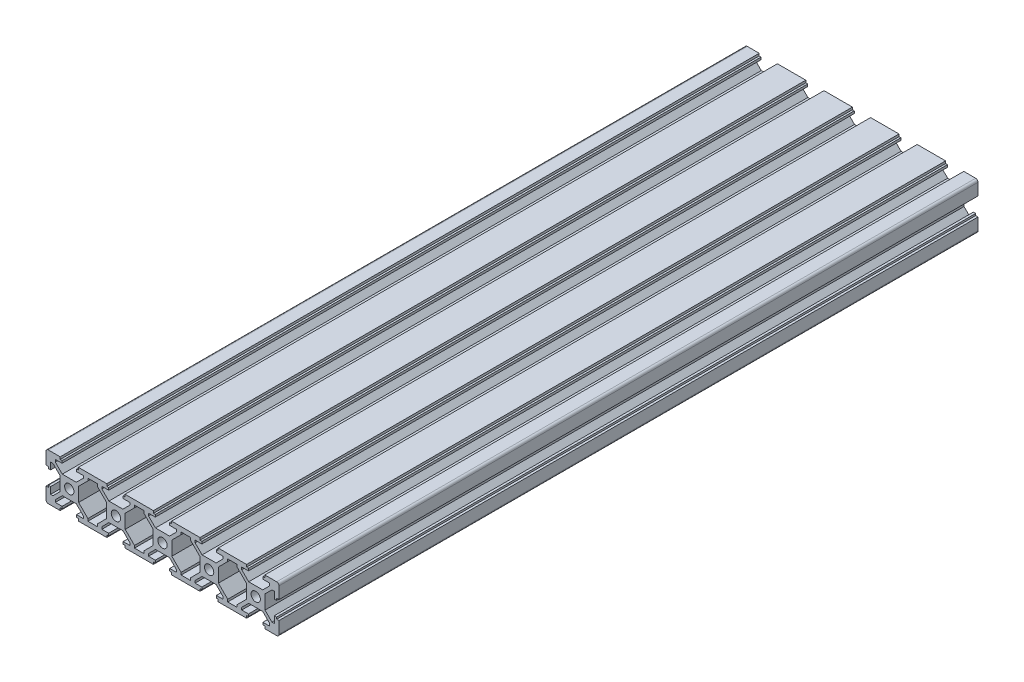
from build123d import *

# Parameters (mm, degrees)
SKETCH_1_R      = 2
EXTRUDE_1_DEPTH = 300
FILLET_1_R      = 1


with BuildPart() as part:
    # Sketch 1 → Extrude 1 (new body)
    with BuildSketch(Plane.XY):
        Polygon((-20, 10), (-13.9, 10), (-13.9, 8.996845012), (-13.1, 8.996845012), (-13.1, 8), (-16.004631122, 8), (-16.004631122, 6.994580616), (-13.010050506, 4), (-6.989949494, 4), (-3.995368878, 6.994580616), (-3.995368878, 8), (-6.9, 8), (-6.9, 8.996845012), (-6.1, 8.996845012), (-6.1, 10), (6.1, 10), (6.1, 8.996845012), (6.9, 8.996845012), (6.9, 8), (3.995368878, 8), (3.995368878, 6.994580616), (6.989949494, 4), (13.010050506, 4), (16.004631122, 6.994580616), (16.004631122, 8), (13.1, 8), (13.1, 8.996845012), (13.9, 8.996845012), (13.9, 10), (26.1, 10), (26.1, 8.996845012), (26.9, 8.996845012), (26.9, 8), (23.995368878, 8), (23.995368878, 6.994580616), (26.989949494, 4), (33.010050506, 4), (36.004631122, 6.994580616), (36.004631122, 8), (33.1, 8), (33.1, 8.996845012), (33.9, 8.996845012), (33.9, 10), (46.1, 10), (46.1, 8.996845012), (46.9, 8.996845012), (46.9, 8), (43.995368878, 8), (43.995368878, 6.994580616), (46.989949494, 4), (53.010050506, 4), (56.004631122, 6.994580616), (56.004631122, 8), (53.1, 8), (53.1, 8.996845012), (53.9, 8.996845012), (53.9, 10), (66.1, 10), (66.1, 8.996845012), (66.9, 8.996845012), (66.9, 8), (63.995368878, 8), (63.995368878, 6.994580616), (66.989949494, 4), (73.010050506, 4), (76.004631122, 6.994580616), (76.004631122, 8), (73.1, 8), (73.1, 8.996845012), (73.9, 8.996845012), (73.9, 10), (80, 10), (80, 3.9), (78.996845012, 3.9), (78.996845012, 3.09747601), (78, 3.09747601), (78, 6), (76.989949494, 6), (74, 3.010050506), (74, -3.010050506), (76.989949494, -6), (78, -6), (78, -3.09747601), (78.996845012, -3.09747601), (78.996845012, -3.9), (80, -3.9), (80, -10), (73.9, -10), (73.9, -8.996845012), (73.1, -8.996845012), (73.1, -8), (76.004631122, -8), (76.004631122, -6.994580616), (73.010050506, -4), (66.989949494, -4), (63.995368878, -6.994580616), (63.995368878, -8), (66.9, -8), (66.9, -8.996845012), (66.1, -8.996845012), (66.1, -10), (53.9, -10), (53.9, -8.996845012), (53.1, -8.996845012), (53.1, -8), (56.004631122, -8), (56.004631122, -6.994580616), (53.010050506, -4), (46.989949494, -4), (43.995368878, -6.994580616), (43.995368878, -8), (46.9, -8), (46.9, -8.996845012), (46.1, -8.996845012), (46.1, -10), (33.9, -10), (33.9, -8.996845012), (33.1, -8.996845012), (33.1, -8), (36.004631122, -8), (36.004631122, -6.994580616), (33.010050506, -4), (26.989949494, -4), (23.995368878, -6.994580616), (23.995368878, -8), (26.9, -8), (26.9, -8.996845012), (26.1, -8.996845012), (26.1, -10), (13.9, -10), (13.9, -8.996845012), (13.1, -8.996845012), (13.1, -8), (16.004631122, -8), (16.004631122, -6.994580616), (13.010050506, -4), (6.989949494, -4), (3.995368878, -6.994580616), (3.995368878, -8), (6.9, -8), (6.9, -8.996845012), (6.1, -8.996845012), (6.1, -10), (-6.1, -10), (-6.1, -8.996845012), (-6.9, -8.996845012), (-6.9, -8), (-3.995368878, -8), (-3.995368878, -6.994580616), (-6.989949494, -4), (-13.010050506, -4), (-16.004631122, -6.994580616), (-16.004631122, -8), (-13.1, -8), (-13.1, -8.996845012), (-13.9, -8.996845012), (-13.9, -10), (-20, -10), (-20, -3.9), (-18.996845012, -3.9), (-18.996845012, -3.09747601), (-18, -3.09747601), (-18, -6), (-16.989949494, -6), (-14, -3.010050506), (-14, 3.010050506), (-16.989949494, 6), (-18, 6), (-18, 3.09747601), (-18.996845012, 3.09747601), (-18.996845012, 3.9), (-20, 3.9), align=None)
        with Locations((-10, 0)):
            Circle(SKETCH_1_R, mode=Mode.SUBTRACT)
        with Locations((10, 0)):
            Circle(SKETCH_1_R, mode=Mode.SUBTRACT)
        with Locations((30, 0)):
            Circle(SKETCH_1_R, mode=Mode.SUBTRACT)
        with Locations((50, 0)):
            Circle(SKETCH_1_R, mode=Mode.SUBTRACT)
        with Locations((70, 0)):
            Circle(SKETCH_1_R, mode=Mode.SUBTRACT)
        Polygon((22.015469891, 8), (17.984530109, 8), (17.984530109, 6.994580616), (14, 3.010050506), (14, -3.010050506), (17.984530109, -6.994580616), (17.984530109, -8), (22.015469891, -8), (22.015469891, -6.994580616), (26, -3.010050506), (26, 3.010050506), (22.015469891, 6.994580616), align=None, mode=Mode.SUBTRACT)
        Polygon((42.015469891, 8), (37.984530109, 8), (37.984530109, 6.994580616), (34, 3.010050506), (34, -3.010050506), (37.984530109, -6.994580616), (37.984530109, -8), (42.015469891, -8), (42.015469891, -6.994580616), (46, -3.010050506), (46, 3.010050506), (42.015469891, 6.994580616), align=None, mode=Mode.SUBTRACT)
        Polygon((62.015469891, 8), (57.984530109, 8), (57.984530109, 6.994580616), (54, 3.010050506), (54, -3.010050506), (57.984530109, -6.994580616), (57.984530109, -8), (62.015469891, -8), (62.015469891, -6.994580616), (66, -3.010050506), (66, 3.010050506), (62.015469891, 6.994580616), align=None, mode=Mode.SUBTRACT)
        Polygon((2.015469891, -8), (2.015469891, -6.994580616), (6, -3.010050506), (6, 3.010050506), (2.015469891, 6.994580616), (2.015469891, 8), (-2.015469891, 8), (-2.015469891, 6.994580616), (-6, 3.010050506), (-6, -3.010050506), (-2.015469891, -6.994580616), (-2.015469891, -8), align=None, mode=Mode.SUBTRACT)
    extrude(amount=EXTRUDE_1_DEPTH)

    # Fillet 1
    fillet_1_edges = [part.edges().sort_by_distance(p)[0] for p in [
        (80, 10, 150),
        (80, -10, 150),
        (-20, -10, 150),
        (-20, 10, 150),
    ]]
    fillet(fillet_1_edges, radius=FILLET_1_R)


solid = part.part
